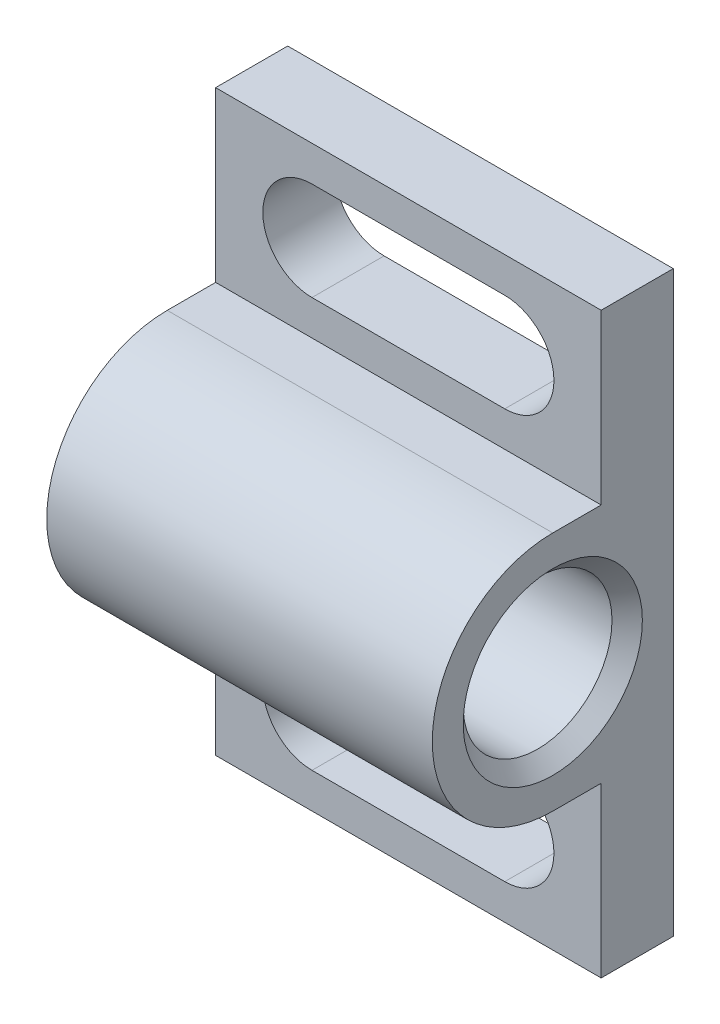
from build123d import *

# Parameters (mm, degrees)
BOSS_EXTRUDE1_DEPTH = 25.4
CUT_EXTRUDE2_REACH  = 37.498


with BuildPart() as part:
    # Sketch1 → Boss-Extrude1 (new body)
    with BuildSketch(Plane(origin=(0, 0, 0), x_dir=(0, 0, -1), z_dir=(1, 0, 0))):
        with BuildLine():
            Line((0, -19.05), (0, 19.05))
            Line((0, 19.05), (-4.7498, 19.05))
            Line((-4.7498, 19.05), (-4.7498, 7.9375))
            Line((-4.7498, 7.9375), (-7.9375, 7.9375))
            ThreePointArc((-7.9375, 7.9375), (-15.875, 0), (-7.9375, -7.9375))
            Line((-7.9375, -7.9375), (-4.7498, -7.9375))
            Line((-4.7498, -7.9375), (-4.7498, -19.05))
            Line((-4.7498, -19.05), (0, -19.05))
        make_face()
    extrude(amount=-BOSS_EXTRUDE1_DEPTH)

    # Sketch2 → Cut-Revolve1 (revolve, cut)
    with BuildSketch(Plane(origin=(0, 0, 0), x_dir=(1, 0, 0), z_dir=(0, 1, 0)), mode=Mode.PRIVATE) as cut_revolve1_sk:
        Polygon((-25.4, -7.9375), (-25.4, -10.4902), (-19.05, -10.4902), (-19.05, -12.8397), (-1, -12.8397), (0, -13.8397), (0, -7.9375), align=None)
    revolve(cut_revolve1_sk.sketch.rotate(Axis((0, 0, 7.9375), (-1, 0, 0)), 180), axis=Axis((0, 0, 7.9375), (-1, 0, 0)), mode=Mode.SUBTRACT)

    # Sketch3 → Cut-Extrude2 (cut, up to next)
    with BuildSketch(Plane.XY, mode=Mode.PRIVATE) as cut_extrude2_sk1:
        with BuildLine():
            Line((-19.05, 16.7259), (-6.35, 16.7259))
            ThreePointArc((-6.35, 16.7259), (-3.1115, 13.4874), (-6.35, 10.2489))
            Line((-6.35, 10.2489), (-19.05, 10.2489))
            ThreePointArc((-19.05, 10.2489), (-22.2885, 13.4874), (-19.05, 16.7259))
        make_face()
    cut_extrude2_tool1 = extrude(cut_extrude2_sk1.sketch, amount=CUT_EXTRUDE2_REACH, mode=Mode.PRIVATE) & part.part
    # Sketch3 → Cut-Extrude2 (cut, up to next)
    with BuildSketch(Plane.XY, mode=Mode.PRIVATE) as cut_extrude2_sk2:
        with BuildLine():
            Line((-19.05, -16.7259), (-6.35, -16.7259))
            ThreePointArc((-6.35, -16.7259), (-3.1115, -13.4874), (-6.35, -10.2489))
            Line((-6.35, -10.2489), (-19.05, -10.2489))
            ThreePointArc((-19.05, -10.2489), (-22.2885, -13.4874), (-19.05, -16.7259))
        make_face()
    cut_extrude2_tool2 = extrude(cut_extrude2_sk2.sketch, amount=CUT_EXTRUDE2_REACH, mode=Mode.PRIVATE) & part.part
    add(cut_extrude2_tool1.solids().sort_by_distance((-12.7, 13.4874, 0))[0], mode=Mode.SUBTRACT)
    add(cut_extrude2_tool2.solids().sort_by_distance((-12.7, -13.4874, 0))[0], mode=Mode.SUBTRACT)


solid = part.part
